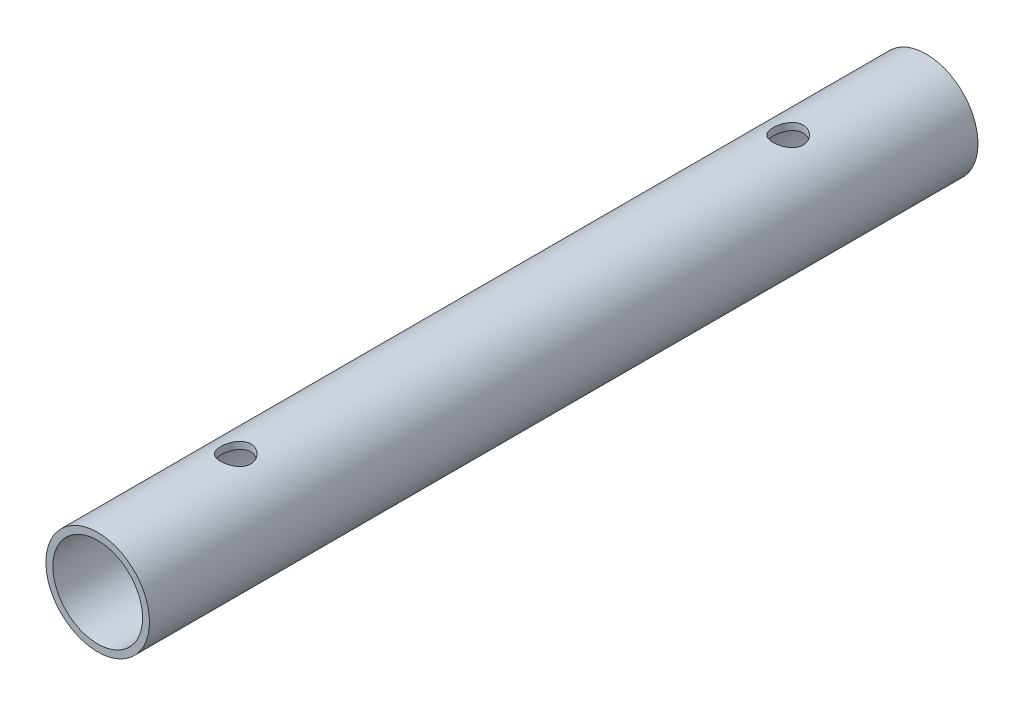
from build123d import *

# Parameters (mm, degrees)
SKETCH1_R           = 19.05
SKETCH1_R_2         = 16.51
EXTRUDE_THIN1_DEPTH = 304.8
SKETCH2_R           = 5.55625
CUT_EXTRUDE1_DEPTH  = 20.05


with BuildPart() as part:
    # Sketch1 → Extrude-Thin1 (new body)
    with BuildSketch(Plane.XY):
        Circle(SKETCH1_R)
        Circle(SKETCH1_R_2, mode=Mode.SUBTRACT)
    extrude(amount=-EXTRUDE_THIN1_DEPTH)

    # Sketch2 → Cut-Extrude1 (cut, through all)
    with BuildSketch(Plane(origin=(0, 0, 0), x_dir=(1, 0, 0), z_dir=(0, 1, 0))):
        with Locations((0, 50.8)):
            Circle(SKETCH2_R)
        with Locations((0, 254)):
            Circle(SKETCH2_R)
    extrude(amount=CUT_EXTRUDE1_DEPTH, mode=Mode.SUBTRACT)


solid = part.part
